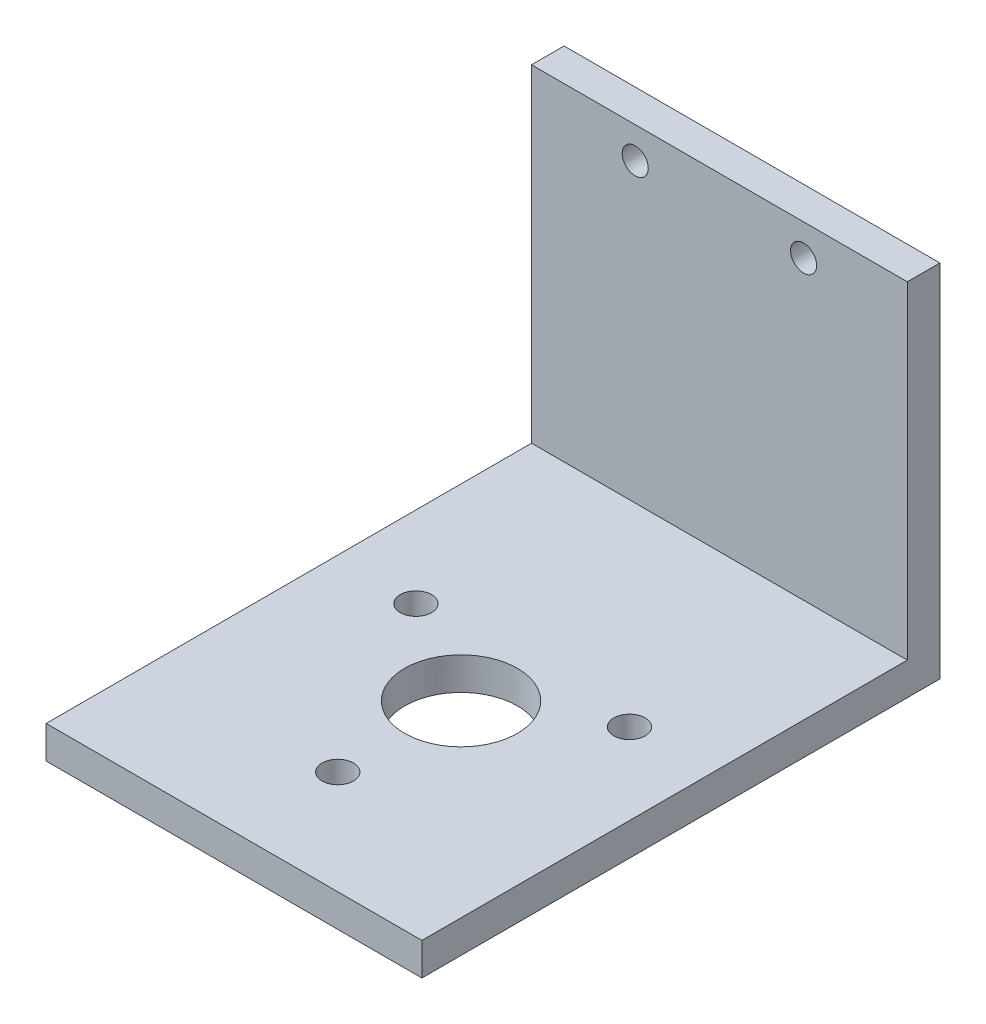
from build123d import *

# Parameters (mm, degrees)
SKETCH1_W           = 76.2
SKETCH1_H           = 73.0504
SKETCH1_R           = 2.6416
BOSS_EXTRUDE1_DEPTH = 6.604
SKETCH2_W           = 76.2
SKETCH2_H           = 6.604
BOSS_EXTRUDE2_DEPTH = 98.425
SKETCH3_R           = 11.43
SKETCH3_R_2         = 3.175
CUT_EXTRUDE1_DEPTH  = 76.2


with BuildPart() as part:
    # Sketch1 → Boss-Extrude1 (new body)
    with BuildSketch(Plane.XY):
        with Locations((38.1, 36.5252)):
            Rectangle(SKETCH1_W, SKETCH1_H)
        with Locations((21.0312, 66.7004)):
            Circle(SKETCH1_R, mode=Mode.SUBTRACT)
        with Locations((55.1688, 66.7004)):
            Circle(SKETCH1_R, mode=Mode.SUBTRACT)
    extrude(amount=-BOSS_EXTRUDE1_DEPTH)

    # Sketch2 → Boss-Extrude2 (add)
    with BuildSketch(Plane.XY):
        with Locations((38.1, 3.302)):
            Rectangle(SKETCH2_W, SKETCH2_H)
    extrude(amount=BOSS_EXTRUDE2_DEPTH)

    # Sketch3 → Cut-Extrude1 (cut)
    with BuildSketch(Plane(origin=(0, 6.604, 0), x_dir=(1, 0, 0), z_dir=(0, 1, 0))):
        with Locations((38.1, -52.3875)):
            Circle(SKETCH3_R)
        with Locations((38.1, -77.3875)):
            Circle(SKETCH3_R_2)
        with Locations((16.449364905, -39.8875)):
            Circle(SKETCH3_R_2)
        with Locations((59.750635095, -39.8875)):
            Circle(SKETCH3_R_2)
    extrude(amount=-CUT_EXTRUDE1_DEPTH, mode=Mode.SUBTRACT)


solid = part.part
